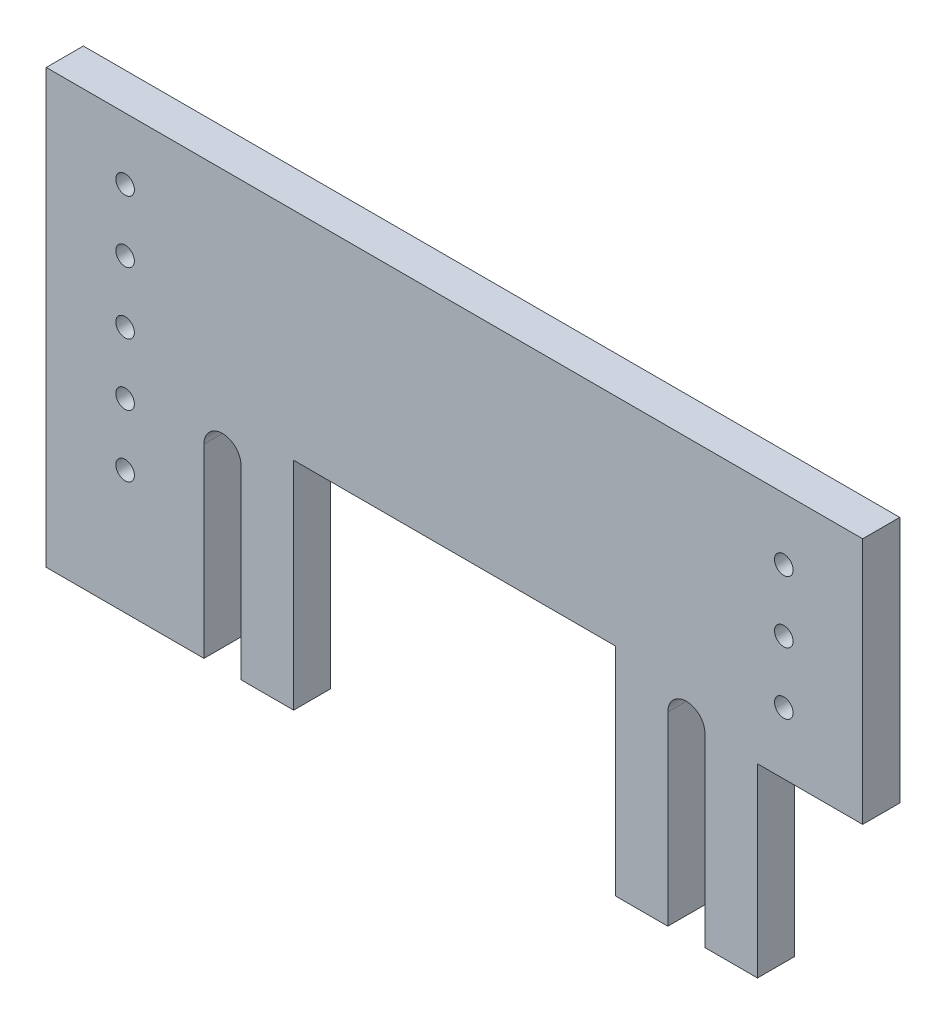
from build123d import *

# Parameters (mm, degrees)
ESBO_O1_R                = 1.5
RESSALTO_EXTRUS_O1_DEPTH = 6


with BuildPart() as part:
    # Esboço1 → Ressalto-extrusão1 (new body)
    with BuildSketch(Plane.XY):
        with BuildLine():
            Line((-66, -35), (-40.5, -35))
            Line((-40.5, -35), (-40.5, -5))
            ThreePointArc((-40.5, -5), (-37.5, -2), (-34.5, -5))
            Line((-34.5, -5), (-34.5, -35))
            Line((-34.5, -35), (-26, -35))
            Line((-26, -35), (-26, 0))
            Line((-26, 0), (26, 0))
            Line((26, 0), (26, -35))
            Line((26, -35), (34.5, -35))
            Line((34.5, -35), (34.5, -5))
            ThreePointArc((34.5, -5), (37.5, -2), (40.5, -5))
            Line((40.5, -5), (40.5, -35))
            Line((40.5, -35), (49, -35))
            Line((49, -35), (49, -5))
            Line((49, -5), (66, -5))
            Line((66, -5), (66, 35))
            Line((66, 35), (-66, 35))
            Line((-66, 35), (-66, -35))
        make_face()
        with Locations((-53.25, -5)):
            Circle(ESBO_O1_R, mode=Mode.SUBTRACT)
        with Locations((-53.25, -15)):
            Circle(ESBO_O1_R, mode=Mode.SUBTRACT)
        with Locations((-53.25, 15)):
            Circle(ESBO_O1_R, mode=Mode.SUBTRACT)
        with Locations((-53.25, 25)):
            Circle(ESBO_O1_R, mode=Mode.SUBTRACT)
        with Locations((-53.25, 5)):
            Circle(ESBO_O1_R, mode=Mode.SUBTRACT)
        with Locations((53.25, 5)):
            Circle(ESBO_O1_R, mode=Mode.SUBTRACT)
        with Locations((53.25, 25)):
            Circle(ESBO_O1_R, mode=Mode.SUBTRACT)
        with Locations((53.25, 15)):
            Circle(ESBO_O1_R, mode=Mode.SUBTRACT)
    extrude(amount=RESSALTO_EXTRUS_O1_DEPTH)


solid = part.part
